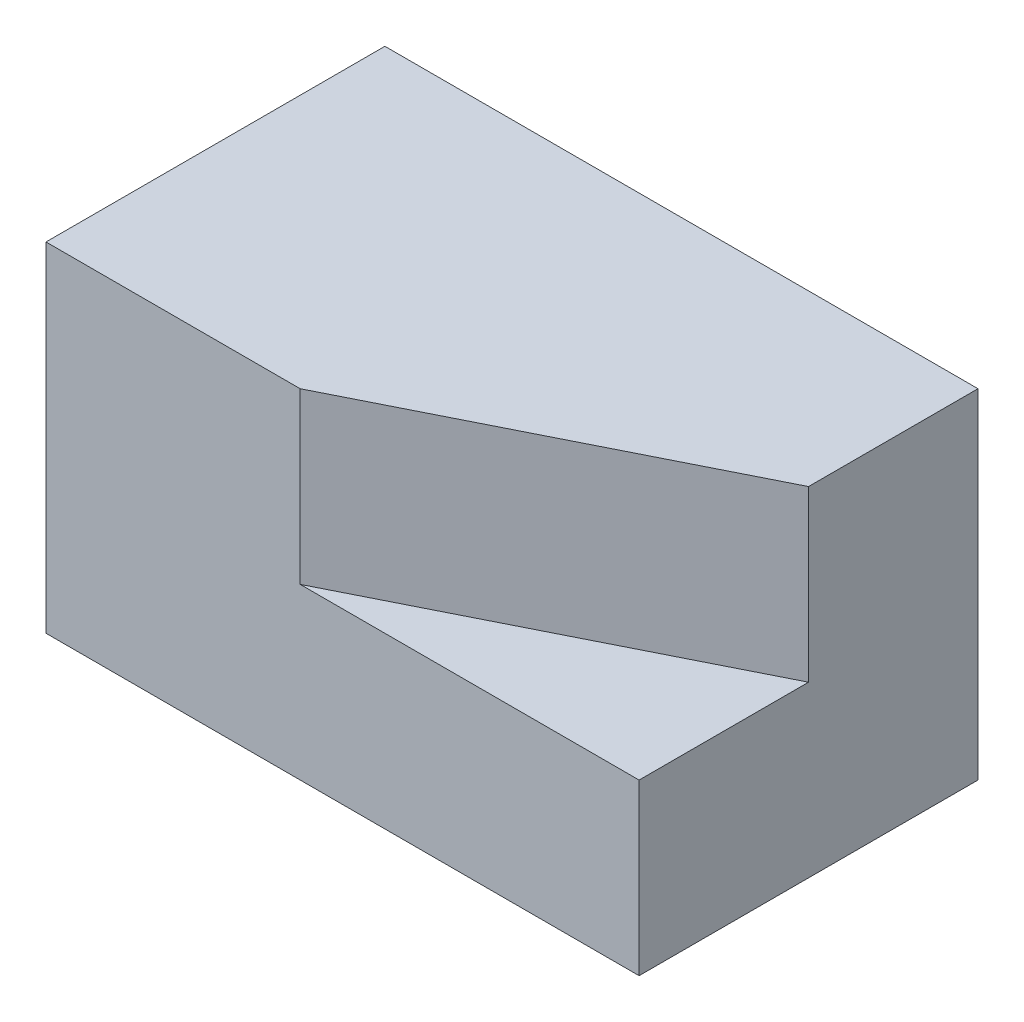
from build123d import *

# Parameters (mm, degrees)
SKETCH1_W           = 177.8
SKETCH1_H           = 50.8
BOSS_EXTRUDE2_DEPTH = 101.6
SKETCH5_W           = 101.6
SKETCH5_H           = 50.8
BOSS_EXTRUDE3_DEPTH = 76.2
BOSS_EXTRUDE4_DEPTH = 50.8
BOSS_EXTRUDE5_REACH = 103.6
SKETCH6_W           = 101.6
SKETCH6_H           = 50.8


with BuildPart() as part:
    # Sketch1 → Boss-Extrude2 (new body)
    with BuildSketch(Plane.XY):
        with Locations((88.9, 25.4)):
            Rectangle(SKETCH1_W, SKETCH1_H)
    extrude(amount=-BOSS_EXTRUDE2_DEPTH)

    # Sketch5 → Boss-Extrude3 (add)
    with BuildSketch(Plane(origin=(0, 0, 0), x_dir=(0, 0, -1), z_dir=(1, 0, 0))):
        with Locations((50.8, 76.2)):
            Rectangle(SKETCH5_W, SKETCH5_H)
    extrude(amount=BOSS_EXTRUDE3_DEPTH)

    # Sketch4 → Boss-Extrude4 (add)
    with BuildSketch(Plane(origin=(0, 50.8, 0), x_dir=(1, 0, 0), z_dir=(0, 1, 0))):
        Polygon((76.2, 50.8), (76.2, 0), (177.8, 50.8), (177.8, 101.6), (177.395806452, 101.6), (177.395806452, 50.8), align=None)
    extrude(amount=BOSS_EXTRUDE4_DEPTH)

    # Sketch6 → Boss-Extrude5 (add, up to next)
    with BuildSketch(Plane(origin=(76.2, 101.6, -101.6), x_dir=(1, 0, 0), z_dir=(0, 0, 1)), mode=Mode.PRIVATE) as boss_extrude5_sk1:
        with Locations((50.8, -25.4)):
            Rectangle(SKETCH6_W, SKETCH6_H)
    boss_extrude5_tool1 = extrude(boss_extrude5_sk1.sketch, amount=BOSS_EXTRUDE5_REACH, mode=Mode.PRIVATE) - part.part
    add(boss_extrude5_tool1.solids().sort_by_distance((127, 76.2, -101.6))[0])


solid = part.part
